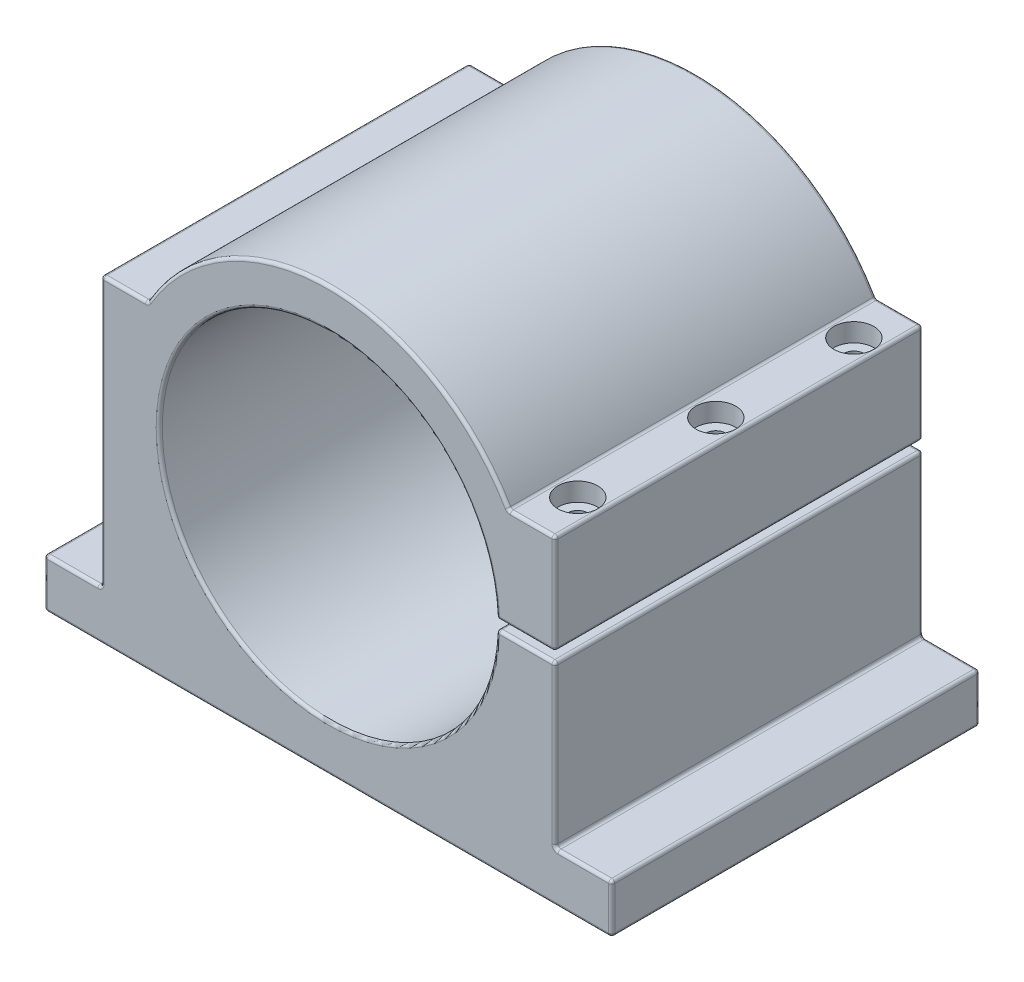
from build123d import *

# Parameters (mm, degrees)
EXTRUDE_1_DEPTH     = 60
SKETCH_2_R          = 6.5
CUT_EXTRUDE_1_DEPTH = 6
SKETCH_3_R          = 3.25
CUT_EXTRUDE_2_DEPTH = 35.5
SKETCH_4_R          = 2.35
CUT_EXTRUDE_3_DEPTH = 30
FILLET_1_R          = 1


with BuildPart() as part:
    # Эскиз1 → Бобышка-Вытянуть1 (new body, symmetric)
    with BuildSketch(Plane.XY):
        with BuildLine():
            Line((-92.5, -70), (92.5, -70))
            Line((92.5, -70), (92.5, -54))
            Line((92.5, -54), (74, -54))
            Line((74, -54), (74, -1.5))
            Line((74, -1.5), (54.97954165, -1.5))
            ThreePointArc((54.97954165, -1.5), (-55, 0), (54.97954165, 1.5))
            Line((54.97954165, 1.5), (74, 1.5))
            Line((74, 1.5), (74, 34))
            Line((74, 34), (58.889727457, 34))
            ThreePointArc((58.889727457, 34), (0, 68), (-58.889727457, 34))
            Line((-58.889727457, 34), (-74, 34))
            Line((-74, 34), (-74, -54))
            Line((-74, -54), (-92.5, -54))
            Line((-92.5, -54), (-92.5, -70))
        make_face()
    extrude(amount=EXTRUDE_1_DEPTH, both=True)

    # Эскиз2 → Вырез-Вытянуть1 (cut)
    with BuildSketch(Plane(origin=(0, 34, 0), x_dir=(1, 0, 0), z_dir=(0, 1, 0))):
        with Locations((66.444863729, 45)):
            Circle(SKETCH_2_R)
        with Locations((66.444863729, 0)):
            Circle(SKETCH_2_R)
        with Locations((66.444863729, -45)):
            Circle(SKETCH_2_R)
    extrude(amount=-CUT_EXTRUDE_1_DEPTH, mode=Mode.SUBTRACT)

    # Эскиз3 → Вырез-Вытянуть2 (cut)
    with BuildSketch(Plane(origin=(0, 34, 0), x_dir=(1, 0, 0), z_dir=(0, 1, 0))):
        with Locations((66.444863729, 45)):
            Circle(SKETCH_3_R)
        with Locations((66.444863729, 0)):
            Circle(SKETCH_3_R)
        with Locations((66.444863729, -45)):
            Circle(SKETCH_3_R)
    extrude(amount=-CUT_EXTRUDE_2_DEPTH, mode=Mode.SUBTRACT)

    # Эскиз4 → Вырез-Вытянуть3 (cut)
    with BuildSketch(Plane(origin=(0, -1.5, 0), x_dir=(1, 0, 0), z_dir=(0, 1, 0))):
        with Locations((66.444863729, 45)):
            Circle(SKETCH_4_R)
        with Locations((66.444863729, 0)):
            Circle(SKETCH_4_R)
        with Locations((66.444863729, -45)):
            Circle(SKETCH_4_R)
    extrude(amount=-CUT_EXTRUDE_3_DEPTH, mode=Mode.SUBTRACT)

    # Скругление1
    fillet_1_edges = [part.edges().sort_by_distance(p)[0] for p in [
        (74, -27.75, -60),
        (83.25, -54, -60),
        (92.5, -62, -60),
        (64.489770825, 1.5, 60),
        (0, -70, -60),
        (-92.5, -62, -60),
        (-83.25, -54, -60),
        (-74, -10, -60),
        (-66.444863729, 34, -60),
        (0, 68, -60),
        (66.444863729, 34, -60),
        (74, 17.75, -60),
        (64.489770825, 1.5, -60),
        (-55, 0, -60),
        (74, 17.75, 60),
        (64.489770825, -1.5, -60),
        (66.444863729, 34, 60),
        (74, -1.5, 0),
        (74, -54, 0),
        (92.5, -54, 0),
        (92.5, -70, 0),
        (-92.5, -70, 0),
        (-92.5, -54, 0),
        (-74, -54, 0),
        (-74, 34, 0),
        (-58.889727457, 34, 0),
        (58.889727457, 34, 0),
        (74, 34, 0),
        (74, 1.5, 0),
        (54.97954165, 1.5, 0),
        (54.97954165, -1.5, 0),
        (0, 68, 60),
        (-66.444863729, 34, 60),
        (-74, -10, 60),
        (64.489770825, -1.5, 60),
        (-83.25, -54, 60),
        (-92.5, -62, 60),
        (0, -70, 60),
        (92.5, -62, 60),
        (83.25, -54, 60),
        (74, -27.75, 60),
        (-55, 0, 60),
    ]]
    fillet(fillet_1_edges, radius=FILLET_1_R)


solid = part.part
